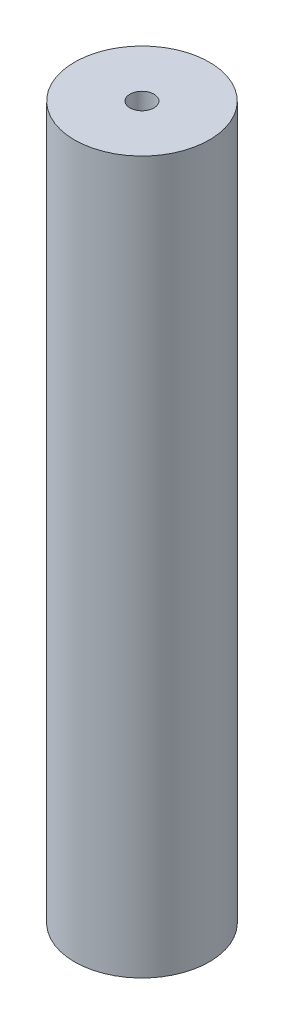
from build123d import *

# Parameters (mm, degrees)
SKETCH1_R           = 6.35
SKETCH1_R_2         = 1.1303
BOSS_EXTRUDE1_DEPTH = 67.056


with BuildPart() as part:
    # Sketch1 → Boss-Extrude1 (new body)
    with BuildSketch(Plane(origin=(0, 0, 0), x_dir=(1, 0, 0), z_dir=(0, 1, 0))):
        Circle(SKETCH1_R)
        Circle(SKETCH1_R_2, mode=Mode.SUBTRACT)
    extrude(amount=BOSS_EXTRUDE1_DEPTH)


solid = part.part
